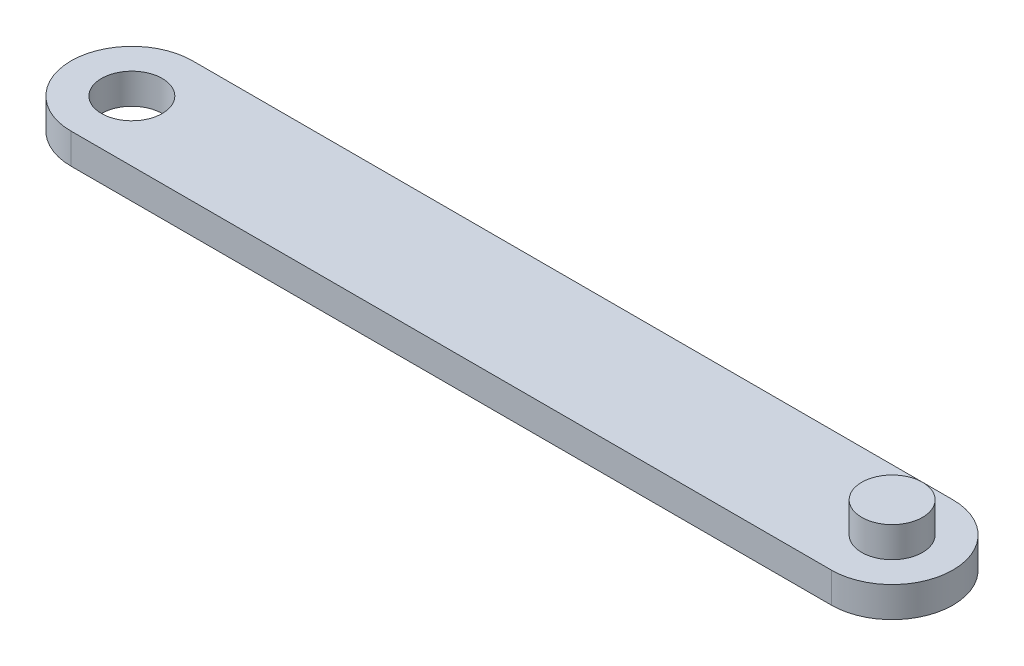
from build123d import *

# Parameters (mm, degrees)
SKETCH1_R           = 1
BOSS_EXTRUDE3_DEPTH = 1
SKETCH3_R           = 1
BOSS_EXTRUDE4_DEPTH = 1
SKETCH4_R           = 1
BOSS_EXTRUDE5_DEPTH = 1


with BuildPart() as part:
    # Sketch1 → Boss-Extrude3 (new body)
    with BuildSketch(Plane(origin=(0, 0, 0), x_dir=(1, 0, 0), z_dir=(0, 1, 0))):
        with BuildLine():
            Line((-12.5, 2), (12.5, 2))
            ThreePointArc((12.5, 2), (14.5, 0), (12.5, -2))
            Line((12.5, -2), (-12.5, -2))
            ThreePointArc((-12.5, -2), (-14.5, 0), (-12.5, 2))
        make_face()
        with Locations((-12.5, 0)):
            Circle(SKETCH1_R, mode=Mode.SUBTRACT)
        with Locations((12.5, 0)):
            Circle(SKETCH1_R, mode=Mode.SUBTRACT)
    extrude(amount=BOSS_EXTRUDE3_DEPTH)

    # Sketch3 → Boss-Extrude4 (add, symmetric)
    with BuildSketch(Plane(origin=(0, 1, 0), x_dir=(1, 0, 0), z_dir=(0, 1, 0))):
        with Locations((12.5, 0)):
            Circle(SKETCH3_R)
    extrude(amount=BOSS_EXTRUDE4_DEPTH, both=True)

    # Sketch4 → Boss-Extrude5 (add)
    with BuildSketch(Plane(origin=(0, 1, 0), x_dir=(1, 0, 0), z_dir=(0, 1, 0))):
        with Locations((12.5, 0)):
            Circle(SKETCH4_R)
    extrude(amount=BOSS_EXTRUDE5_DEPTH)


solid = part.part
